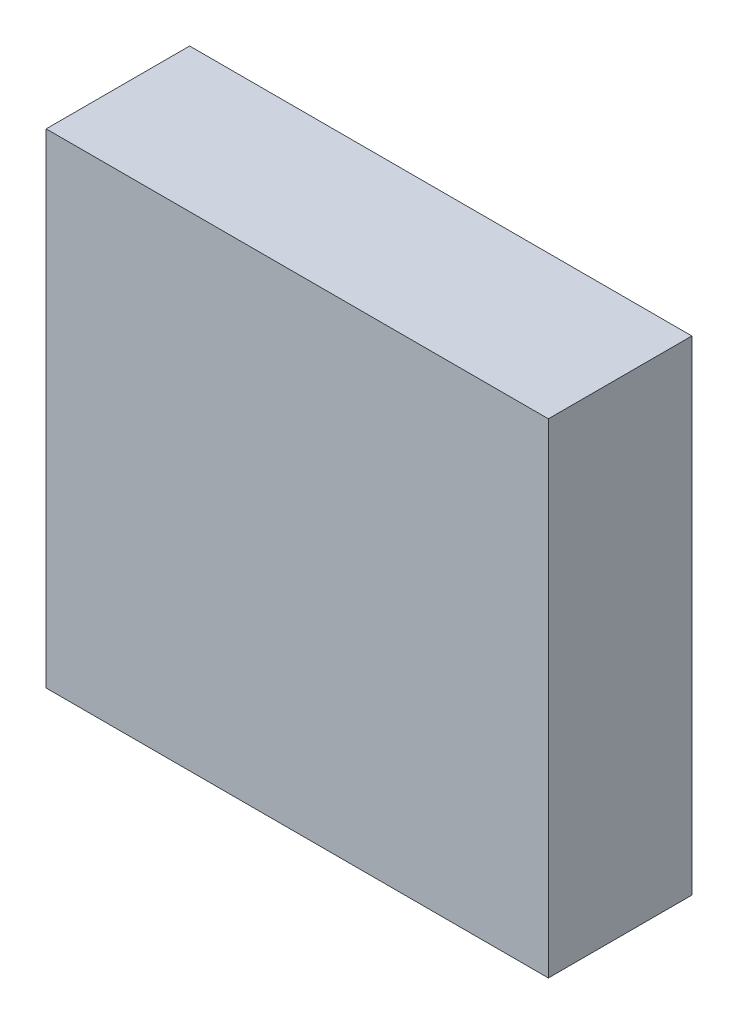
from build123d import *

# Parameters (mm, degrees)
SKETCH_1_W      = 28
SKETCH_1_H      = 27
EXTRUDE_1_DEPTH = 8


with BuildPart() as part:
    # 草图1 → 凸台-拉伸1 (new body)
    with BuildSketch(Plane.XY):
        with Locations((-14, -13.5)):
            Rectangle(SKETCH_1_W, SKETCH_1_H)
    extrude(amount=EXTRUDE_1_DEPTH)


solid = part.part
